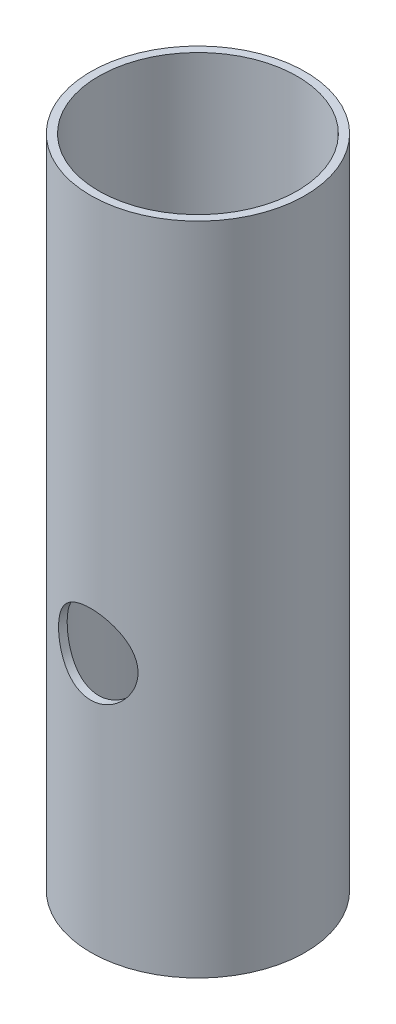
from build123d import *

# Parameters (mm, degrees)
SKETCH1_R           = 27
BOSS_EXTRUDE1_DEPTH = 5
SKETCH2_R           = 27
SKETCH2_R_2         = 25
BOSS_EXTRUDE2_DEPTH = 160
SKETCH3_R           = 5
CUT_EXTRUDE1_DEPTH  = 160
SKETCH4_R           = 10
CUT_EXTRUDE6_DEPTH  = 41


with BuildPart() as part:
    # Sketch1 → Boss-Extrude1 (new body)
    with BuildSketch(Plane(origin=(0, 0, 0), x_dir=(1, 0, 0), z_dir=(0, 1, 0))):
        Circle(SKETCH1_R)
    extrude(amount=BOSS_EXTRUDE1_DEPTH)

    # Sketch2 → Boss-Extrude2 (add)
    with BuildSketch(Plane(origin=(0, 5, 0), x_dir=(1, 0, 0), z_dir=(0, 1, 0))):
        Circle(SKETCH2_R)
        Circle(SKETCH2_R_2, mode=Mode.SUBTRACT)
    extrude(amount=BOSS_EXTRUDE2_DEPTH)

    # Sketch3 → Cut-Extrude1 (cut)
    with BuildSketch(Plane.XY):
        with Locations((0, 20)):
            Circle(SKETCH3_R)
    extrude(amount=-CUT_EXTRUDE1_DEPTH, mode=Mode.SUBTRACT)

    # Sketch4 → Cut-Extrude6 (cut)
    with BuildSketch(Plane.XY):
        with Locations((0, 65)):
            Circle(SKETCH4_R)
    extrude(amount=CUT_EXTRUDE6_DEPTH, mode=Mode.SUBTRACT)


solid = part.part
